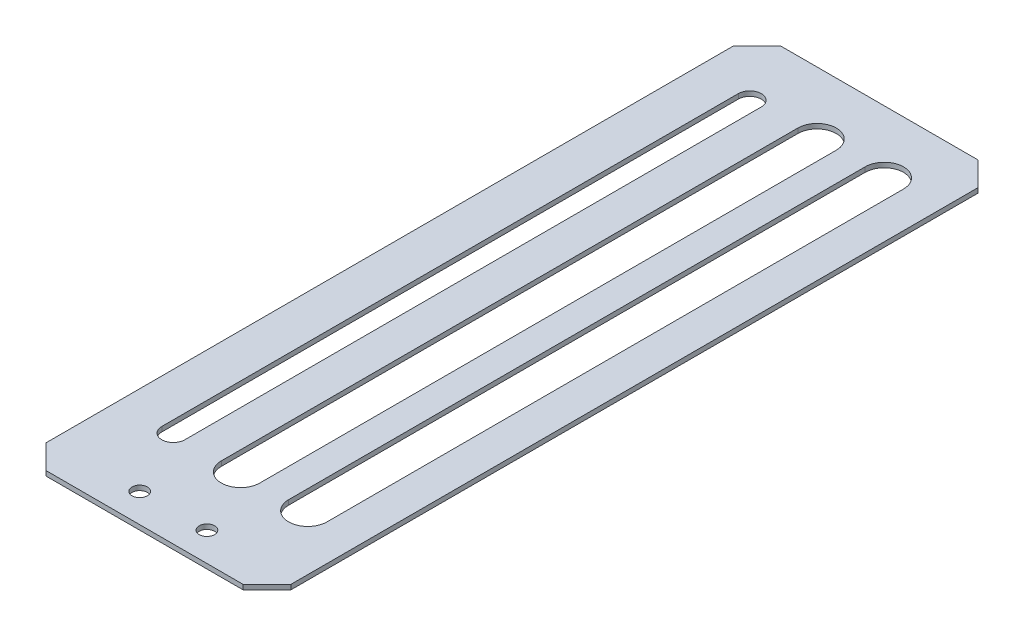
from build123d import *

# Parameters (mm, degrees)
SKETCH_1_W          = 51
SKETCH_1_H          = 153
EXTRUDE_1_DEPTH     = 1
SKETCH_2_R          = 1.6
CUT_EXTRUDE_1_DEPTH = 2
CHAMFER_1_SIZE      = 5
EXTRUDE_2_DEPTH     = 1


with BuildPart() as part:
    # 草图1 → 凸台-拉伸1 (new body)
    with BuildSketch(Plane(origin=(0, 0, 0), x_dir=(1, 0, 0), z_dir=(0, 1, 0))):
        Rectangle(SKETCH_1_W, SKETCH_1_H)
    extrude(amount=EXTRUDE_1_DEPTH)

    # 草图2 → 切除-拉伸1 (cut, through all)
    with BuildSketch(Plane(origin=(0, 1, 0), x_dir=(1, 0, 0), z_dir=(0, 1, 0))):
        with Locations((-7, -70.5)):
            Circle(SKETCH_2_R)
        with Locations((7, -70.5)):
            Circle(SKETCH_2_R)
        with BuildLine():
            Line((-10, 63.5), (-10, -56.5))
            ThreePointArc((-10, -56.5), (-14, -60.5), (-18, -56.5))
            Line((-18, -56.5), (-18, 63.5))
            ThreePointArc((-18, 63.5), (-14, 67.5), (-10, 63.5))
        make_face()
        with BuildLine():
            Line((4, 63.5), (4, -56.5))
            ThreePointArc((4, -56.5), (0, -60.5), (-4, -56.5))
            Line((-4, -56.5), (-4, 63.5))
            ThreePointArc((-4, 63.5), (0, 67.5), (4, 63.5))
        make_face()
        with BuildLine():
            Line((18, 63.5), (18, -56.5))
            ThreePointArc((18, -56.5), (14, -60.5), (10, -56.5))
            Line((10, -56.5), (10, 63.5))
            ThreePointArc((10, 63.5), (14, 67.5), (18, 63.5))
        make_face()
    extrude(amount=-CUT_EXTRUDE_1_DEPTH, mode=Mode.SUBTRACT)

    # 倒角1
    chamfer_1_edges = [part.edges().sort_by_distance(p)[0] for p in [
        (-25.5, 0.5, -76.5),
        (25.5, 0.5, -76.5),
        (25.5, 0.5, 76.5),
        (-25.5, 0.5, 76.5),
    ]]
    chamfer(chamfer_1_edges, length=CHAMFER_1_SIZE)

    # 草图4 → 凸台-拉伸2 (add)
    with BuildSketch(Plane(origin=(0, 1, 0), x_dir=(1, 0, 0), z_dir=(0, 1, 0))):
        with BuildLine():
            Line((-10, -56.5), (-10, 63.5))
            ThreePointArc((-10, 63.5), (-14, 67.5), (-18, 63.5))
            Line((-18, 63.5), (-18, -56.5))
            ThreePointArc((-18, -56.5), (-14, -60.5), (-10, -56.5))
        make_face()
        with BuildLine():
            Line((-11.6, 63.5), (-11.6, -56.5))
            ThreePointArc((-11.6, -56.5), (-14, -58.9), (-16.4, -56.5))
            Line((-16.4, -56.5), (-16.4, 63.5))
            ThreePointArc((-16.4, 63.5), (-14, 65.9), (-11.6, 63.5))
        make_face(mode=Mode.SUBTRACT)
    extrude(amount=-EXTRUDE_2_DEPTH)


solid = part.part
